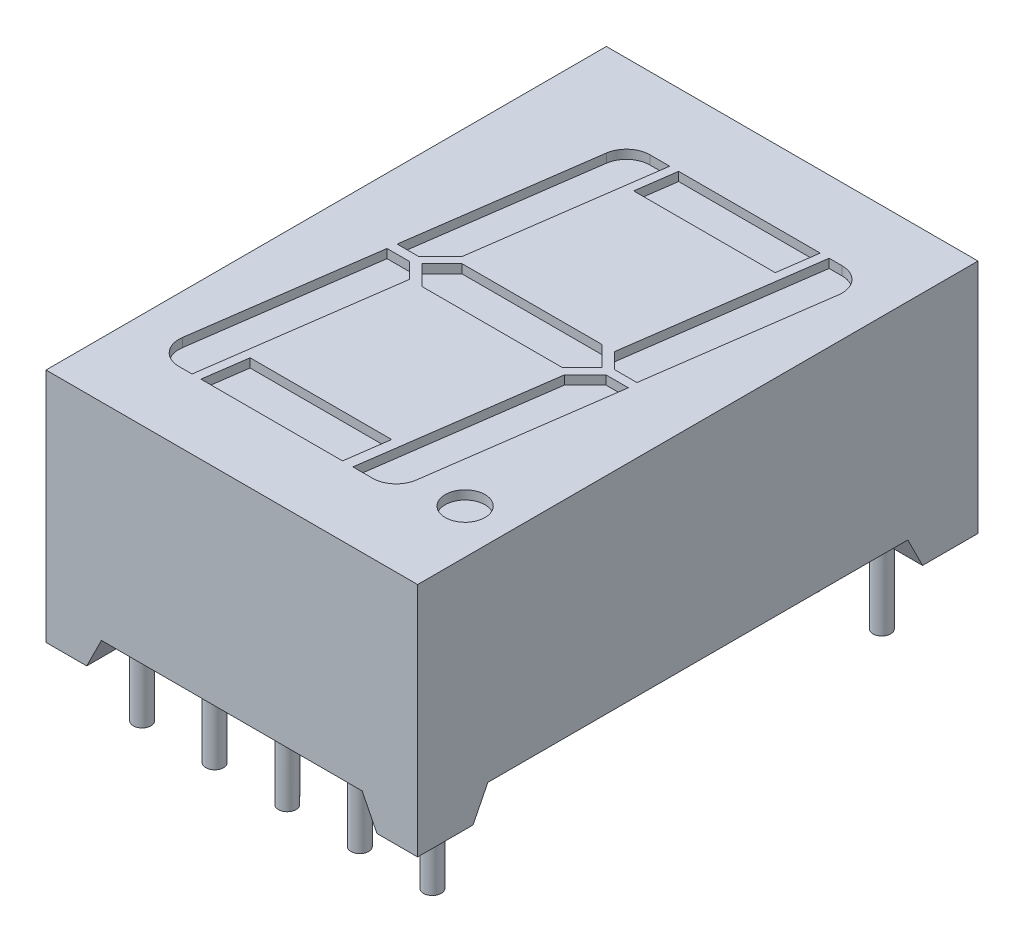
from build123d import *

# Parameters (mm, degrees)
SKETCH1_W           = 12.6
SKETCH1_H           = 19
BOSS_EXTRUDE1_DEPTH = 8
CUT_EXTRUDE1_DEPTH  = 20
CUT_EXTRUDE2_DEPTH  = 13.6
SKETCH4_R           = 0.675
CUT_EXTRUDE3_DEPTH  = 0.3
SKETCH5_R           = 0.3
BOSS_EXTRUDE2_DEPTH = 3.55


with BuildPart() as part:
    # Sketch1 → Boss-Extrude1 (new body)
    with BuildSketch(Plane(origin=(0, 0, 0), x_dir=(1, 0, 0), z_dir=(0, 1, 0))):
        Rectangle(SKETCH1_W, SKETCH1_H)
    extrude(amount=BOSS_EXTRUDE1_DEPTH)

    # Sketch2 → Cut-Extrude1 (cut, through all)
    with BuildSketch(Plane.XY.offset(9.5)):
        Polygon((-4.92, 0), (4.92, 0), (4.42, 1), (-4.42, 1), align=None)
    extrude(amount=-CUT_EXTRUDE1_DEPTH, mode=Mode.SUBTRACT)

    # Sketch3 → Cut-Extrude2 (cut, through all)
    with BuildSketch(Plane.ZY.offset(6.3)):
        Polygon((-7.62, 0), (7.62, 0), (7.12, 1), (-7.12, 1), align=None)
    extrude(amount=-CUT_EXTRUDE2_DEPTH, mode=Mode.SUBTRACT)

    # Sketch4 → Cut-Extrude3 (cut)
    with BuildSketch(Plane(origin=(0, 8, 0), x_dir=(1, 0, 0), z_dir=(0, 1, 0))):
        with Locations((4.8, -6.39)):
            Circle(SKETCH4_R)
        Polygon((-1.408090595, 7.057802146), (3.391909405, 7.057802146), (3.204025719, 5.720940254), (-1.595974281, 5.720940254), align=None)
        Polygon((-3.198514004, -5.681722368), (1.601485996, -5.681722368), (1.396229552, -7.142197854), (-3.403770448, -7.142197854), align=None)
        Polygon((-3.048549266, 0), (-2.373549266, 0.675), (2.373549266, 0.675), (3.048549266, 0), (2.373549266, -0.675), (-2.373549266, -0.675), align=None)
        with BuildLine():
            Line((3.694857677, 7.057802146), (2.797813335, 0.675))
            Line((2.797813335, 0.675), (3.322813335, 0.15))
            Line((3.322813335, 0.15), (4.08729662, 0.15))
            Line((4.08729662, 0.15), (4.930044629, 6.146463666))
            ThreePointArc((4.930044629, 6.146463666), (4.741597838, 6.78264937), (4.137830174, 7.057802146))
            Line((4.137830174, 7.057802146), (3.694857677, 7.057802146))
        make_face()
        with BuildLine():
            Line((3.339208356, -0.15), (4.094226883, -0.15))
            Line((4.094226883, -0.15), (3.208322625, -6.453536334))
            ThreePointArc((3.208322625, -6.453536334), (2.940955393, -6.945965518), (2.41610817, -7.142197854))
            Line((2.41610817, -7.142197854), (1.748270337, -7.142197854))
            Line((1.748270337, -7.142197854), (2.631497367, -0.857710989))
            Line((2.631497367, -0.857710989), (3.339208356, -0.15))
        make_face()
        with BuildLine():
            Line((-1.711038867, 7.057802146), (-2.577058081, 0.895755255))
            Line((-2.577058081, 0.895755255), (-3.322813335, 0.15))
            Line((-3.322813335, 0.15), (-4.045134369, 0.15))
            Line((-4.045134369, 0.15), (-3.171091155, 6.369140627))
            ThreePointArc((-3.171091155, 6.369140627), (-2.903723923, 6.861569811), (-2.3788767, 7.057802146))
            Line((-2.3788767, 7.057802146), (-1.711038867, 7.057802146))
        make_face()
        with BuildLine():
            Line((-4.08729662, -0.15), (-4.941905672, -6.230859373))
            ThreePointArc((-4.941905672, -6.230859373), (-4.753458881, -6.867045077), (-4.149691217, -7.142197854))
            Line((-4.149691217, -7.142197854), (-3.70671872, -7.142197854))
            Line((-3.70671872, -7.142197854), (-2.797813335, -0.675))
            Line((-2.797813335, -0.675), (-3.322813335, -0.15))
            Line((-3.322813335, -0.15), (-4.08729662, -0.15))
        make_face()
    extrude(amount=-CUT_EXTRUDE3_DEPTH, mode=Mode.SUBTRACT)

    # Sketch5 → Boss-Extrude2 (add)
    with BuildSketch(Plane.XZ.offset(-1)):
        with Locations((-4.92, 7.62)):
            Circle(SKETCH5_R)
        with Locations((-2.46, 7.62)):
            Circle(SKETCH5_R)
        with Locations((0, 7.62)):
            Circle(SKETCH5_R)
        with Locations((2.46, 7.62)):
            Circle(SKETCH5_R)
        with Locations((4.92, 7.62)):
            Circle(SKETCH5_R)
        with Locations((-2.46, -7.62)):
            Circle(SKETCH5_R)
        with Locations((0, -7.62)):
            Circle(SKETCH5_R)
        with Locations((2.46, -7.62)):
            Circle(SKETCH5_R)
        with Locations((4.92, -7.62)):
            Circle(SKETCH5_R)
        with Locations((-4.92, -7.62)):
            Circle(SKETCH5_R)
    extrude(amount=BOSS_EXTRUDE2_DEPTH)


solid = part.part
